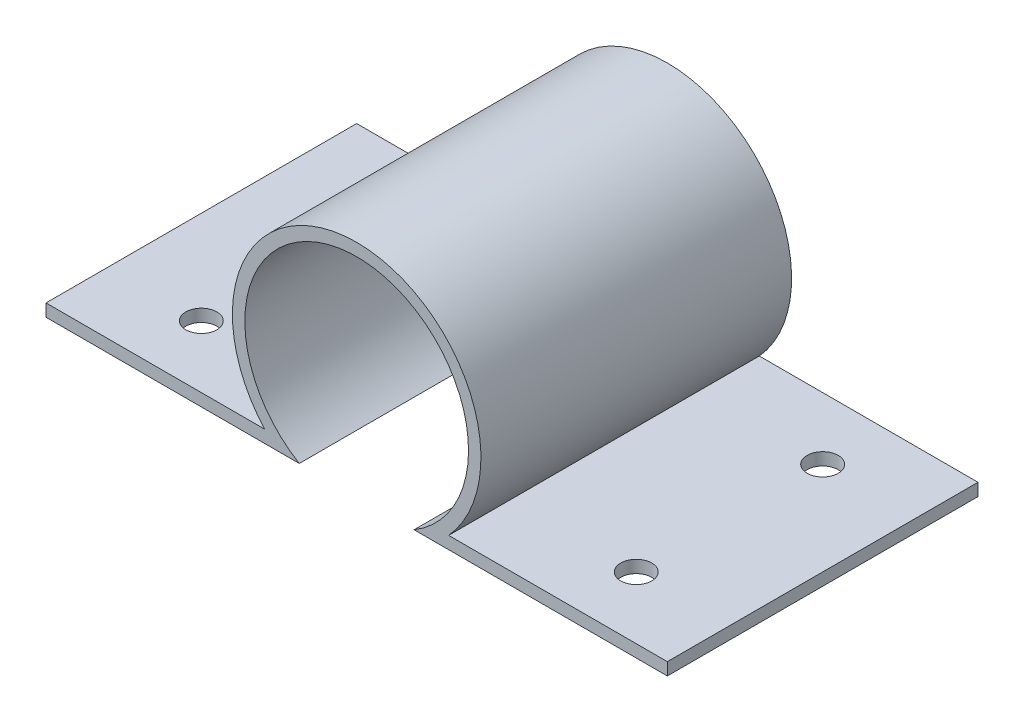
from build123d import *

# Parameters (mm, degrees)
BOSS_EXTRUDE2_DEPTH = 50
SKETCH3_R           = 2.5
CUT_EXTRUDE2_DEPTH  = 50


with BuildPart() as part:
    # Sketch1 → Boss-Extrude2 (new body)
    with BuildSketch(Plane.XY):
        with BuildLine():
            Line((-50, 0), (-14.803348106, 0))
            ThreePointArc((-14.803348106, 0), (0, 33.448452879), (14.803348106, 0))
            Line((14.803348106, 0), (50, 0))
            Line((50, 0), (50, -2))
            Line((50, -2), (9.238252196, -2))
            ThreePointArc((9.238252196, -2), (0, 31.448452879), (-9.238252196, -2))
            Line((-9.238252196, -2), (-50, -2))
            Line((-50, -2), (-50, 0))
        make_face()
    extrude(amount=BOSS_EXTRUDE2_DEPTH)

    # Sketch3 → Cut-Extrude2 (cut)
    with BuildSketch(Plane(origin=(0, 0, 0), x_dir=(1, 0, 0), z_dir=(0, 1, 0))):
        with Locations((35, -10)):
            Circle(SKETCH3_R)
        with Locations((35, -40)):
            Circle(SKETCH3_R)
        with Locations((-35, -40)):
            Circle(SKETCH3_R)
        with Locations((-35, -10)):
            Circle(SKETCH3_R)
    extrude(amount=-CUT_EXTRUDE2_DEPTH, mode=Mode.SUBTRACT)


solid = part.part
